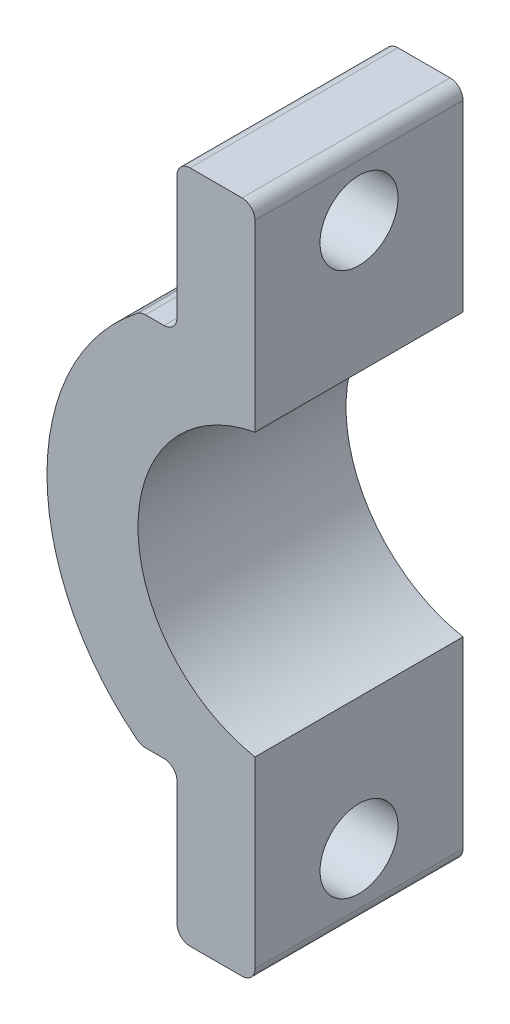
from build123d import *

# Parameters (mm, degrees)
ESQUISSE1_R             = 13
ESQUISSE1_R_2           = 5.5
BOSS_EXTRU_1_DEPTH      = 8
ESQUISSE2_W             = 32.31004566
ESQUISSE2_H             = 49.818141682
ENL_V_MAT_EXTRU_1_DEPTH = 8
ESQUISSE3_R             = 1.5
ENL_V_MAT_EXTRU_2_DEPTH = 8
ESQUISSE4_W             = 24.87123002
ESQUISSE4_H             = 13.833010023
ESQUISSE4_W_2           = 23.432073676
ESQUISSE4_H_2           = 10.309386407
ENL_V_MAT_EXTRU_3_DEPTH = 8
ENL_V_MAT_EXTRU_4_DEPTH = 8
ESQUISSE7_W             = 3
ESQUISSE7_H             = 5.75
BOSS_EXTRU_3_DEPTH      = 8
ESQUISSE11_R            = 1.5
ENL_V_MAT_EXTRU_5_DEPTH = 8
CONG_5_R                = 0.5
CONG_6_R                = 0.5
CONG_7_R                = 0.5
CONG_8_R                = 0.5


with BuildPart() as part:
    # Esquisse1 → Boss.-Extru.1 (new body)
    with BuildSketch(Plane.XY):
        Circle(ESQUISSE1_R)
        Circle(ESQUISSE1_R_2, mode=Mode.SUBTRACT)
    extrude(amount=BOSS_EXTRU_1_DEPTH)

    # Esquisse2 → Enlèv. mat.-Extru.1 (cut)
    with BuildSketch(Plane.XY.offset(8)):
        with Locations((15.15502283, -0.665904075)):
            Rectangle(ESQUISSE2_W, ESQUISSE2_H)
    extrude(amount=-ENL_V_MAT_EXTRU_1_DEPTH, mode=Mode.SUBTRACT)

    # Esquisse3 → Enlèv. mat.-Extru.2 (cut)
    with BuildSketch(Plane(origin=(-1, 0, 0), x_dir=(0, 0, -1), z_dir=(1, 0, 0))):
        with Locations((-4, 10.461481397)):
            Circle(ESQUISSE3_R)
        with Locations((-4, -10.461481397)):
            Circle(ESQUISSE3_R)
    extrude(amount=-ENL_V_MAT_EXTRU_2_DEPTH, mode=Mode.SUBTRACT)

    # Esquisse4 → Enlèv. mat.-Extru.3 (cut)
    with BuildSketch(Plane.XY.offset(8)):
        with Locations((-16.43561501, 14.127986408)):
            Rectangle(ESQUISSE4_W, ESQUISSE4_H)
        with Locations((-15.716036838, -12.366174601)):
            Rectangle(ESQUISSE4_W_2, ESQUISSE4_H_2)
    extrude(amount=-ENL_V_MAT_EXTRU_3_DEPTH, mode=Mode.SUBTRACT)

    # Esquisse6 → Enlèv. mat.-Extru.4 (cut)
    with BuildSketch(Plane.XY.offset(8)):
        with BuildLine():
            Line((-14.689217928, -10.049334481), (-4.81866764, -7.601344761))
            ThreePointArc((-4.81866764, -7.601344761), (-8.998001154, 0.189671363), (-4.494067947, 7.797650498))
            Line((-4.494067947, 7.797650498), (-11.133481596, 10.892455097))
            ThreePointArc((-11.133481596, 10.892455097), (-17.721132871, 1.238220245), (-14.689217928, -10.049334481))
        make_face()
    extrude(amount=-ENL_V_MAT_EXTRU_4_DEPTH, mode=Mode.SUBTRACT)

    # Esquisse7 → Boss.-Extru.3 (add)
    with BuildSketch(Plane(origin=(0, 0, 0), x_dir=(-1, 0, 0), z_dir=(0, 0, -1))):
        with Locations((2.5, 10.086481397)):
            Rectangle(ESQUISSE7_W, ESQUISSE7_H)
        with Locations((2.5, -10.086481397)):
            Rectangle(ESQUISSE7_W, ESQUISSE7_H)
    extrude(amount=-BOSS_EXTRU_3_DEPTH)

    # Esquisse11 → Enlèv. mat.-Extru.5 (cut)
    with BuildSketch(Plane(origin=(-1, 0, 0), x_dir=(0, 0, -1), z_dir=(1, 0, 0))):
        with Locations((-4, 10.461481397)):
            Circle(ESQUISSE11_R)
        with Locations((-4, -10.461481397)):
            Circle(ESQUISSE11_R)
    extrude(amount=-ENL_V_MAT_EXTRU_5_DEPTH, mode=Mode.SUBTRACT)

    # Congé5
    cong_5_edges = [part.edges().sort_by_distance(p)[0] for p in [
        (-4, 12.961481397, 4),
        (-4, -12.961481397, 4),
    ]]
    fillet(cong_5_edges, radius=CONG_5_R)

    # Congé6
    cong_6_edges = [part.edges().sort_by_distance(p)[0] for p in [
        (-4, 7.211481397, 4),
        (-4, -7.211481397, 4),
    ]]
    fillet(cong_6_edges, radius=CONG_6_R)

    # Congé7
    cong_7_edges = [part.edges().sort_by_distance(p)[0] for p in [
        (-1, 12.961481397, 4),
        (-1, -12.961481397, 4),
    ]]
    fillet(cong_7_edges, radius=CONG_7_R)

    # Congé8
    cong_8_edges = [part.edges().sort_by_distance(p)[0] for p in [
        (-5.384657469, 7.211481397, 4),
        (-5.384657469, -7.211481397, 4),
    ]]
    fillet(cong_8_edges, radius=CONG_8_R)


solid = part.part
